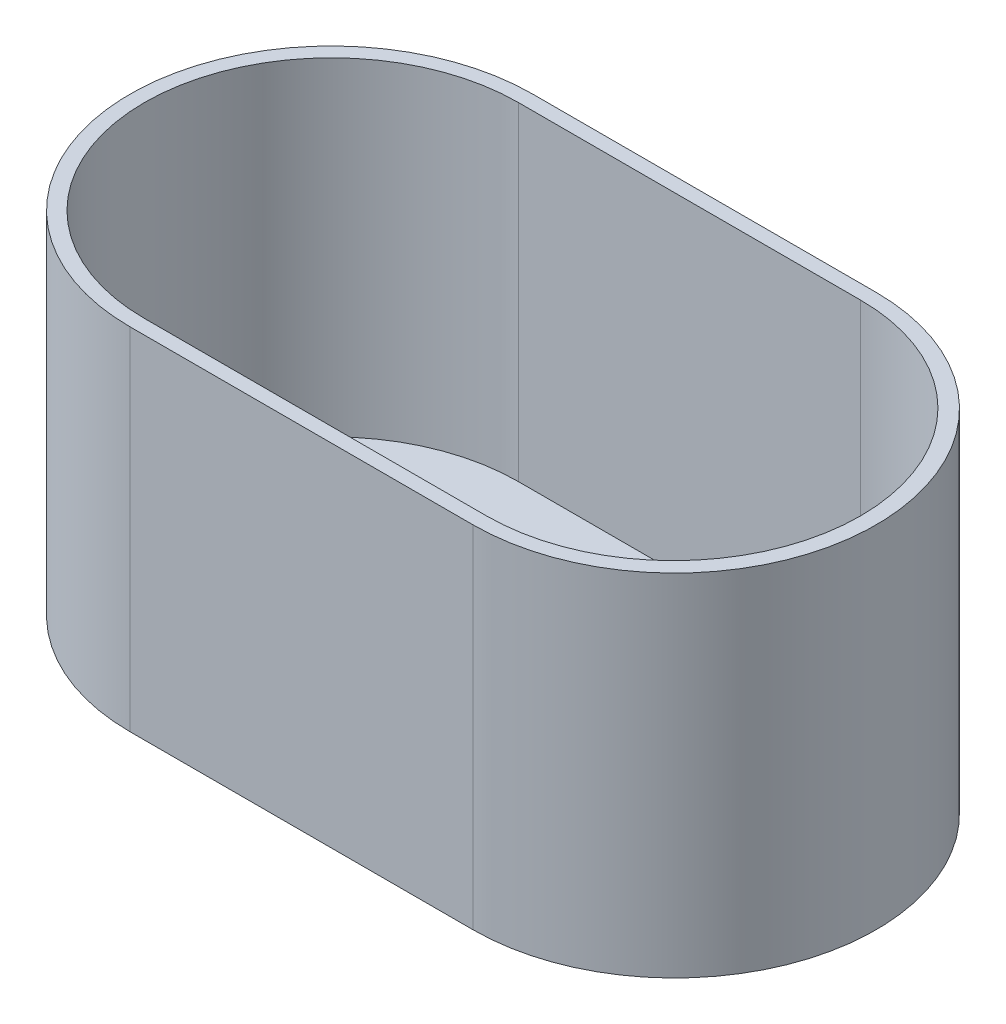
from build123d import *

# Parameters (mm, degrees)
BOSS_EXTRUDE1_DEPTH     = 44
CUT_EXTRUDE1_DEPTH      = 46
CUT_EXTRUDE1_DEPTH_BACK = 2
BOSS_EXTRUDE3_DEPTH     = 3
BOSS_EXTRUDE4_DEPTH     = 3


with BuildPart() as part:
    # Sketch2 → Boss-Extrude1 (new body)
    with BuildSketch(Plane(origin=(0, 0, 0), x_dir=(1, 0, 0), z_dir=(0, 1, 0))):
        with BuildLine():
            Line((0, 27), (46, 27))
            ThreePointArc((46, 27), (73, 0), (46, -27))
            Line((46, -27), (0, -27))
            ThreePointArc((0, -27), (-27, 0), (0, 27))
        make_face()
    extrude(amount=BOSS_EXTRUDE1_DEPTH)

    # Sketch3 → Cut-Extrude1 (cut, two sides)
    with BuildSketch(Plane(origin=(0, 0, 0), x_dir=(1, 0, 0), z_dir=(0, 1, 0))) as cut_extrude1_sk:
        with BuildLine():
            Line((0, 25.059391222), (45.856281638, 25.059391222))
            ThreePointArc((45.856281638, 25.059391222), (70.91567286, 0), (45.856281638, -25.059391222))
            Line((45.856281638, -25.059391222), (0, -25.059391222))
            ThreePointArc((0, -25.059391222), (-25.059391222, 0), (0, 25.059391222))
        make_face()
    extrude(amount=CUT_EXTRUDE1_DEPTH, mode=Mode.SUBTRACT)
    extrude(cut_extrude1_sk.sketch, amount=-CUT_EXTRUDE1_DEPTH_BACK, mode=Mode.SUBTRACT)

    # Sketch4 → Boss-Extrude3 (add)
    with BuildSketch(Plane(origin=(0, 0, 0), x_dir=(1, 0, 0), z_dir=(0, 1, 0))):
        with BuildLine():
            Line((0, 27), (46, 27))
            ThreePointArc((46, 27), (73, 0), (46, -27))
            Line((46, -27), (0, -27))
            ThreePointArc((0, -27), (-27, 0), (0, 27))
        make_face()
    extrude(amount=-BOSS_EXTRUDE3_DEPTH)

    # Sketch5 → Boss-Extrude4 (add)
    with BuildSketch(Plane(origin=(0, 0, 0), x_dir=(1, 0, 0), z_dir=(0, 1, 0))):
        Polygon((-13.939721019, 10.08564224), (-13.939721019, 4.695281904), (-15.675819956, 4.695281904), (-15.675819956, 11.794197793), (-9.286795656, 11.794197793), (-9.286795656, 10.08564224), align=None)
        Polygon((26.347826906, -10.126495255), (26.347826906, -4.736134919), (28.083925843, -4.736134919), (28.083925843, -11.835050808), (21.694901543, -11.835050808), (21.694901543, -10.126495255), align=None)
    extrude(amount=BOSS_EXTRUDE4_DEPTH)


solid = part.part
